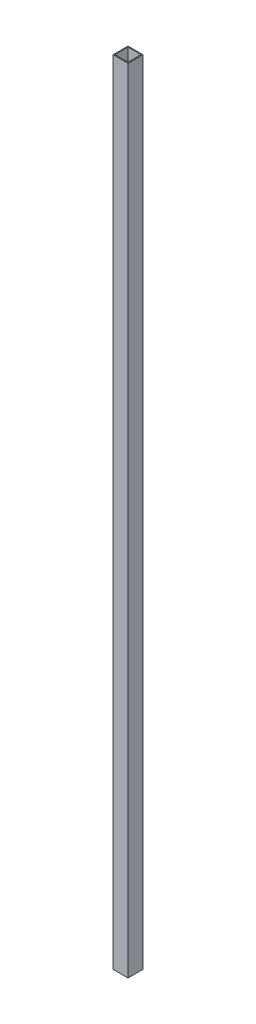
from build123d import *

# Parameters (mm, degrees)
SKETCH2_W           = 30
SKETCH2_H           = 30
SKETCH2_W_2         = 26
SKETCH2_H_2         = 26
BOSS_EXTRUDE1_DEPTH = 793.015


with BuildPart() as part:
    # Sketch2 → Boss-Extrude1 (new body, symmetric)
    with BuildSketch(Plane(origin=(0, 0, 0), x_dir=(1, 0, 0), z_dir=(0, 1, 0))):
        Rectangle(SKETCH2_W, SKETCH2_H)
        Rectangle(SKETCH2_W_2, SKETCH2_H_2, mode=Mode.SUBTRACT)
    extrude(amount=BOSS_EXTRUDE1_DEPTH, both=True)


solid = part.part
